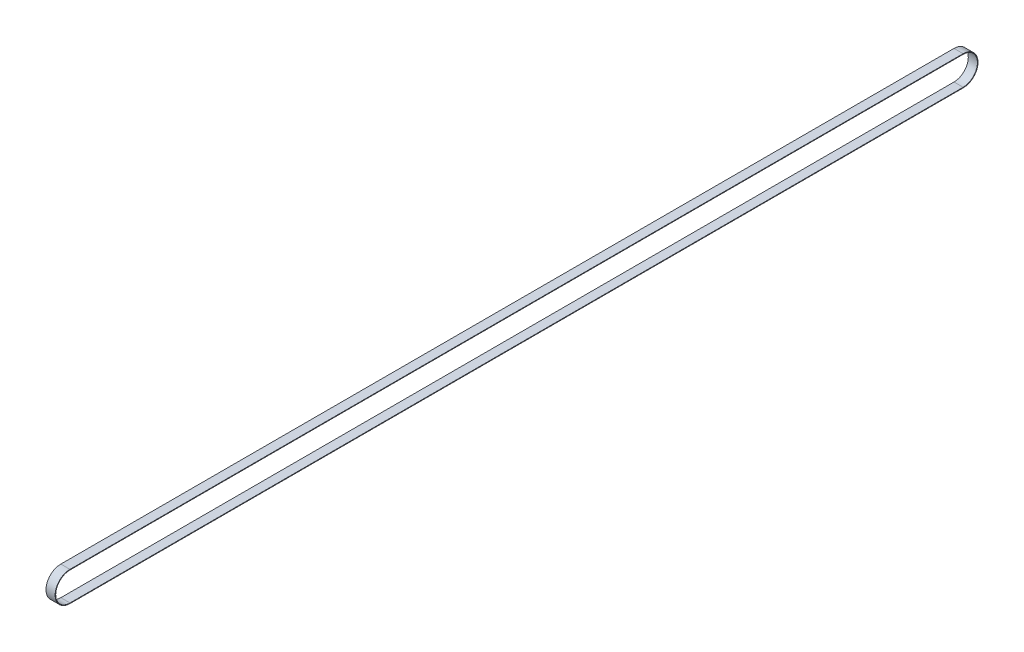
from build123d import *

# Parameters (mm, degrees)
BOSS_EXTRUDE1_DEPTH = 15


with BuildPart() as part:
    # Sketch1 → Boss-Extrude1 (new body)
    with BuildSketch(Plane(origin=(0, 0, 0), x_dir=(0, 0, -1), z_dir=(1, 0, 0))):
        with BuildLine():
            Line((0, 24.35), (1465, 24.35))
            ThreePointArc((1465, 24.35), (1489.35, 0), (1465, -24.35))
            Line((1465, -24.35), (0, -24.35))
            ThreePointArc((0, -24.35), (-24.35, 0), (0, 24.35))
        make_face()
        with BuildLine():
            Line((0, 23.4), (1465, 23.4))
            ThreePointArc((1465, 23.4), (1488.4, 0), (1465, -23.4))
            Line((1465, -23.4), (0, -23.4))
            ThreePointArc((0, -23.4), (-23.4, 0), (0, 23.4))
        make_face(mode=Mode.SUBTRACT)
    extrude(amount=-BOSS_EXTRUDE1_DEPTH)


solid = part.part
